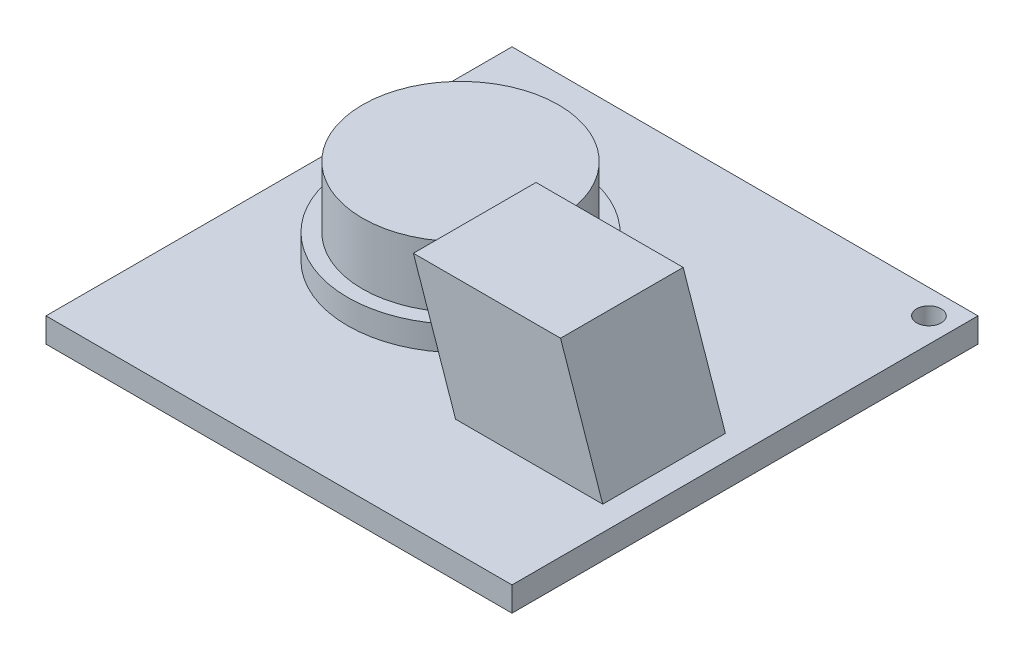
from build123d import *

# Parameters (mm, degrees)
SKETCH_1_W          = 19
SKETCH_1_H          = 19
EXTRUDE_1_DEPTH     = 1
SKETCH_2_R          = 0.5
CUT_EXTRUDE_1_DEPTH = 1
SKETCH_3_R          = 4.6
EXTRUDE_2_DEPTH     = 1
SKETCH_5_R          = 4
EXTRUDE_3_DEPTH     = 2.5
SKETCH_6_W          = 6
SKETCH_6_H          = 5


with BuildPart() as part:
    # Эскиз1 → Бобышка-Вытянуть1 (new body)
    with BuildSketch(Plane(origin=(0, 0, 0), x_dir=(1, 0, 0), z_dir=(0, 1, 0))):
        with Locations((-26.569127832, -17.007177836)):
            Rectangle(SKETCH_1_W, SKETCH_1_H)
    extrude(amount=EXTRUDE_1_DEPTH)

    # Эскиз2 → Вырез-Вытянуть1 (cut)
    with BuildSketch(Plane(origin=(0, 1, 0), x_dir=(1, 0, 0), z_dir=(0, 1, 0))):
        with Locations((-18.069127832, -8.507177836)):
            Circle(SKETCH_2_R)
    extrude(amount=-CUT_EXTRUDE_1_DEPTH, mode=Mode.SUBTRACT)

    # Эскиз3 → Бобышка-Вытянуть2 (add)
    with BuildSketch(Plane(origin=(0, 1, 0), x_dir=(1, 0, 0), z_dir=(0, 1, 0))):
        with Locations((-29.569127832, -16.107177836)):
            Circle(SKETCH_3_R)
    extrude(amount=EXTRUDE_2_DEPTH)

    # Эскиз5 → Бобышка-Вытянуть3 (add)
    with BuildSketch(Plane(origin=(0, 2, 0), x_dir=(1, 0, 0), z_dir=(0, 1, 0))):
        with Locations((-29.569127832, -16.107177836)):
            Circle(SKETCH_5_R)
    extrude(amount=EXTRUDE_3_DEPTH)

    # По траектории1: sweep along a path in Эскиз9
    with BuildLine(Plane.XY) as sweep_1_path:
        Line((-24.069127832, 1), (-25.789600147, 6))
    # Эскиз6 → По траектории1 (sweep)
    with BuildSketch(Plane(origin=(0, 1, 0), x_dir=(1, 0, 0), z_dir=(0, 1, 0))):
        with Locations((-21.069127832, -19.307177836)):
            Rectangle(SKETCH_6_W, SKETCH_6_H)
    sweep(path=sweep_1_path.line)


solid = part.part
